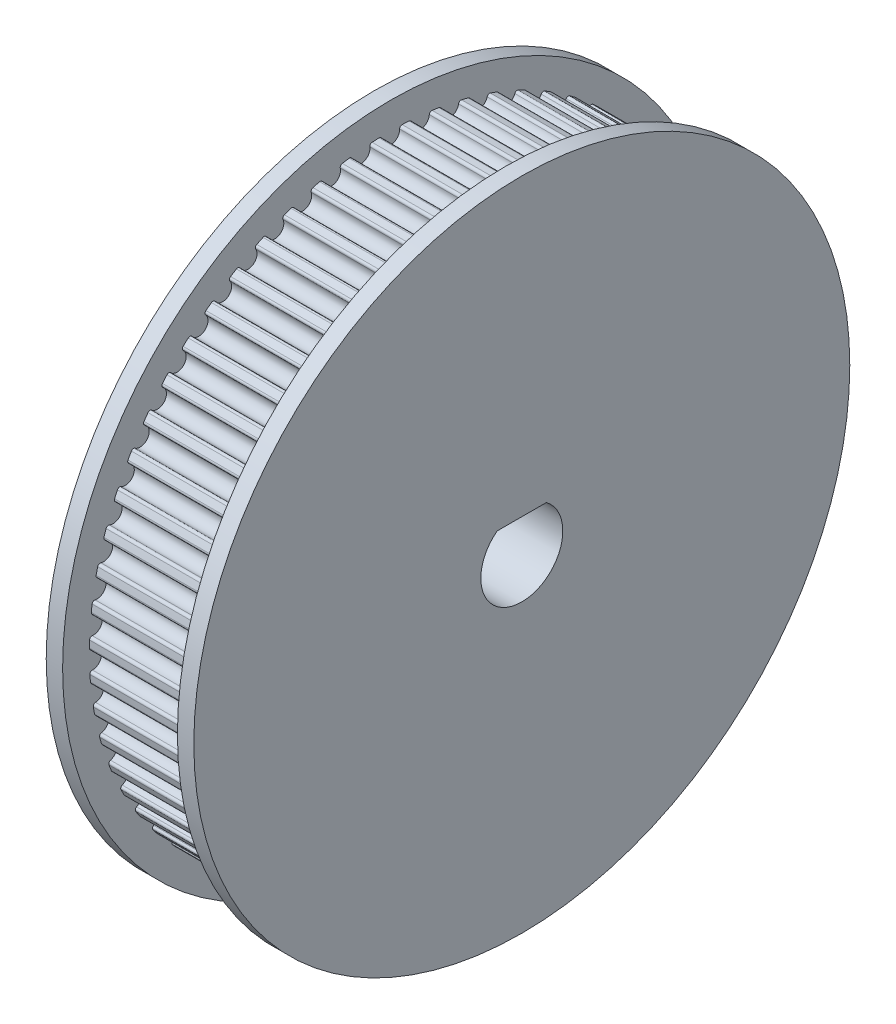
from build123d import *

# Parameters (mm, degrees)
CUT_EXTRUDE3_DEPTH       = 7
FILLET2_R                = 0.15
CIRPATTERN2_COUNT        = 63
FILLET2_OF_CIRPATTERN2_R = 0.15
SKETCH10_W               = 7
SKETCH10_H               = 7.5
CUT_EXTRUDE4_DEPTH       = 8
CUT_EXTRUDE4_DEPTH_BACK  = 10


with BuildPart() as part:
    # Sketch1 → Revolve1 (revolve)
    with BuildSketch(Plane.XY):
        Polygon((0, 0), (9, 0), (9, 20), (8, 20), (8, 18.37), (1, 18.37), (1, 20), (0, 20), align=None)
    revolve(axis=Axis((0, 0, 0), (1, 0, 0)))

    # Sketch8 → Cut-Extrude3 (cut)
    with BuildSketch(Plane(origin=(1, 0, 0), x_dir=(0, 0, -1), z_dir=(1, 0, 0))):
        with BuildLine():
            ThreePointArc((0.518777869, 18.362673267), (0, 18.37), (-0.518777869, 18.362673267))
            ThreePointArc((-0.518777869, 18.362673267), (0, 17.63), (0.518777869, 18.362673267))
        make_face()
    cut_extrude3 = extrude(amount=CUT_EXTRUDE3_DEPTH, mode=Mode.SUBTRACT)

    # Fillet2
    fillet2_edges = [part.edges().sort_by_distance(p)[0] for p in [
        (4.5, 18.362673267, 0.518777869),
        (4.5, 18.362673267, -0.518777869),
    ]]
    fillet(fillet2_edges, radius=FILLET2_R)

    # CirPattern2: Cut-Extrude3 ×63 about axis
    cirpattern2_axis = Axis((0, 0, 0), (1, 0, 0))
    for i in range(1, CIRPATTERN2_COUNT):
        add(cut_extrude3.rotate(cirpattern2_axis, i * 360 / CIRPATTERN2_COUNT), mode=Mode.SUBTRACT)

    # Fillet2 of CirPattern2
    fillet2_of_cirpattern2_edges = [part.edges().sort_by_distance(p)[0] for p in [
        (4.5, 18.219771424, 2.34453178),
        (4.5, 18.323078614, 1.31213189),
        (4.5, 17.895793306, 4.146984681),
        (4.5, 18.101380974, 3.130001092),
        (4.5, 17.393958755, 5.908222985),
        (4.5, 17.699783677, 4.916762938),
        (4.5, 16.719255226, 7.610742715),
        (4.5, 17.122277978, 6.654659784),
        (4.5, 15.878388228, 9.237623465),
        (4.5, 16.374603388, 8.326419632),
        (4.5, 14.879714674, 10.772696562),
        (4.5, 15.464190633, 9.91542778),
        (4.5, 13.733159831, 12.200705761),
        (4.5, 14.400087804, 11.405891953),
        (4.5, 12.450118675, 13.507458864),
        (4.5, 13.192870432, 12.782999247),
        (4.5, 11.043342647, 14.679968773),
        (4.5, 11.854536387, 14.033063352),
        (4.5, 9.526812917, 15.706582558),
        (4.5, 10.398386634, 15.143660568),
        (4.5, 7.915601441, 16.577097268),
        (4.5, 8.838893043, 16.103753282),
        (4.5, 6.225721162, 17.282861338),
        (4.5, 7.191554561, 16.903799661),
        (4.5, 4.473966869, 17.816860567),
        (4.5, 5.47274318, 17.535848485),
        (4.5, 2.677748282, 18.173787831),
        (4.5, 3.699541217, 17.993618168),
        (4.5, 0.854917031, 18.350095827),
        (4.5, 1.889571553, 18.27255919),
        (4.5, -0.97641077, 18.344032327),
        (4.5, 0.060822477, 18.369899309),
        (4.5, -2.798034562, 18.155657592),
        (4.5, -1.76853108, 18.284671116),
        (4.5, -4.59185023, 17.786843775),
        (4.5, -3.580308181, 18.017721647),
        (4.5, -6.340030027, 17.241256313),
        (4.5, -5.35650257, 17.571703965),
        (4.5, -8.025199758, 16.5243175),
        (4.5, -7.07946163, 16.951050794),
        (4.5, -9.630611447, 15.643152596),
        (4.5, -8.73206182, 16.161930465),
        (4.5, -11.140309794, 14.606519014),
        (4.5, -10.297878857, 15.212185611),
        (4.5, -12.539290736, 13.424719283),
        (4.5, -11.761350947, 14.111255221),
        (4.5, -13.813650574, 12.109498661),
        (4.5, -13.107933447, 12.870080837),
        (4.5, -14.950724146, 10.673928401),
        (4.5, -14.324243416, 11.500997808),
        (4.5, -15.939210705, 9.132275844),
        (4.5, -15.398192618, 10.017612695),
        (4.5, -16.769286227, 7.499862628),
        (4.5, -16.319107664, 8.434668047),
        (4.5, -17.432701048, 5.792912407),
        (4.5, -17.077836086, 6.767895878),
        (4.5, -17.922861855, 4.028389621),
        (4.5, -17.666837301, 5.03386132),
        (4.5, -18.234897208, 2.223830888),
        (4.5, -18.080257549, 3.249797986),
        (4.5, -18.36570596, 0.397170725),
        (4.5, -18.313988075, 1.433436699),
        (4.5, -18.313988075, -1.433436699),
        (4.5, -18.36570596, -0.397170725),
        (4.5, -18.080257549, -3.249797986),
        (4.5, -18.234897208, -2.223830888),
        (4.5, -17.666837301, -5.03386132),
        (4.5, -17.922861855, -4.028389621),
        (4.5, -17.077836086, -6.767895878),
        (4.5, -17.432701048, -5.792912407),
        (4.5, -16.319107664, -8.434668047),
        (4.5, -16.769286227, -7.499862628),
        (4.5, -15.398192618, -10.017612695),
        (4.5, -15.939210705, -9.132275844),
        (4.5, -14.324243416, -11.500997808),
        (4.5, -14.950724146, -10.673928401),
        (4.5, -13.107933447, -12.870080837),
        (4.5, -13.813650574, -12.109498661),
        (4.5, -11.761350947, -14.111255221),
        (4.5, -12.539290736, -13.424719283),
        (4.5, -10.297878857, -15.212185611),
        (4.5, -11.140309794, -14.606519014),
        (4.5, -8.73206182, -16.161930465),
        (4.5, -9.630611447, -15.643152596),
        (4.5, -7.07946163, -16.951050794),
        (4.5, -8.025199758, -16.5243175),
        (4.5, -5.35650257, -17.571703965),
        (4.5, -6.340030027, -17.241256313),
        (4.5, -3.580308181, -18.017721647),
        (4.5, -4.59185023, -17.786843775),
        (4.5, -1.76853108, -18.284671116),
        (4.5, -2.798034562, -18.155657592),
        (4.5, 0.060822477, -18.369899309),
        (4.5, -0.97641077, -18.344032327),
        (4.5, 1.889571553, -18.27255919),
        (4.5, 0.854917031, -18.350095827),
        (4.5, 3.699541217, -17.993618168),
        (4.5, 2.677748282, -18.173787831),
        (4.5, 5.47274318, -17.535848485),
        (4.5, 4.473966869, -17.816860567),
        (4.5, 7.191554561, -16.903799661),
        (4.5, 6.225721162, -17.282861338),
        (4.5, 8.838893043, -16.103753282),
        (4.5, 7.915601441, -16.577097268),
        (4.5, 10.398386634, -15.143660568),
        (4.5, 9.526812917, -15.706582558),
        (4.5, 11.854536387, -14.033063352),
        (4.5, 11.043342647, -14.679968773),
        (4.5, 13.192870432, -12.782999247),
        (4.5, 12.450118675, -13.507458864),
        (4.5, 14.400087804, -11.405891953),
        (4.5, 13.733159831, -12.200705761),
        (4.5, 15.464190633, -9.91542778),
        (4.5, 14.879714674, -10.772696562),
        (4.5, 16.374603388, -8.326419632),
        (4.5, 15.878388228, -9.237623465),
        (4.5, 17.122277978, -6.654659784),
        (4.5, 16.719255226, -7.610742715),
        (4.5, 17.699783677, -4.916762938),
        (4.5, 17.393958755, -5.908222985),
        (4.5, 18.101380974, -3.130001092),
        (4.5, 17.895793306, -4.146984681),
        (4.5, 18.323078614, -1.31213189),
        (4.5, 18.219771424, -2.34453178),
    ]]
    fillet(fillet2_of_cirpattern2_edges, radius=FILLET2_OF_CIRPATTERN2_R)

    # Sketch10 → Revolve2 (revolve)
    with BuildSketch(Plane.XY):
        with Locations((-3.5, 3.75)):
            Rectangle(SKETCH10_W, SKETCH10_H)
    revolve(axis=Axis((0, 0, 0), (-1, 0, 0)))

    # Sketch7 → Cut-Extrude4 (cut, two sides)
    with BuildSketch(Plane.ZY) as cut_extrude4_sk:
        with BuildLine():
            Line((0, 2), (1.5, 2))
            ThreePointArc((1.5, 2), (0, -2.5), (-1.5, 2))
            Line((-1.5, 2), (0, 2))
        make_face()
    extrude(amount=CUT_EXTRUDE4_DEPTH, mode=Mode.SUBTRACT)
    extrude(cut_extrude4_sk.sketch, amount=-CUT_EXTRUDE4_DEPTH_BACK, mode=Mode.SUBTRACT)


solid = part.part
